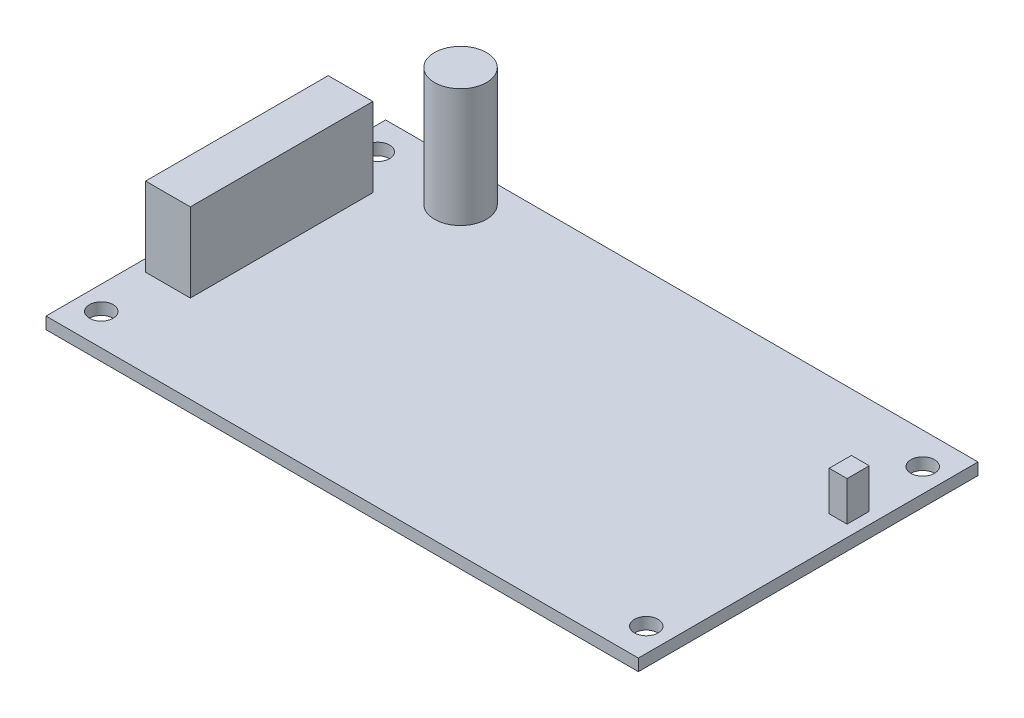
from build123d import *

# Parameters (mm, degrees)
SKETCH1_W           = 75
SKETCH1_H           = 43
SKETCH1_R           = 1.5
BOSS_EXTRUDE1_DEPTH = 1.5
SKETCH3_W           = 5.662945026
SKETCH3_H           = 23.11722764
BOSS_EXTRUDE2_DEPTH = 10
SKETCH4_W           = 2.260398275
SKETCH4_H           = 2.806011651
BOSS_EXTRUDE3_DEPTH = 5
SKETCH5_R           = 3.292125191
BOSS_EXTRUDE4_DEPTH = 15


with BuildPart() as part:
    # Sketch1 → Boss-Extrude1 (new body)
    with BuildSketch(Plane(origin=(0, 0, 0), x_dir=(1, 0, 0), z_dir=(0, 1, 0))):
        Rectangle(SKETCH1_W, SKETCH1_H)
        with Locations((-34.5, 17.5)):
            Circle(SKETCH1_R, mode=Mode.SUBTRACT)
        with Locations((-34.5, -17.5)):
            Circle(SKETCH1_R, mode=Mode.SUBTRACT)
        with Locations((34.5, -17.5)):
            Circle(SKETCH1_R, mode=Mode.SUBTRACT)
        with Locations((34.5, 17.5)):
            Circle(SKETCH1_R, mode=Mode.SUBTRACT)
    extrude(amount=BOSS_EXTRUDE1_DEPTH)

    # Sketch3 → Boss-Extrude2 (add)
    with BuildSketch(Plane(origin=(0, 1.5, 0), x_dir=(1, 0, 0), z_dir=(0, 1, 0))):
        with Locations((-33.163136966, 1.163618841)):
            Rectangle(SKETCH3_W, SKETCH3_H)
    extrude(amount=BOSS_EXTRUDE2_DEPTH)

    # Sketch4 → Boss-Extrude3 (add)
    with BuildSketch(Plane(origin=(0, 1.5, 0), x_dir=(1, 0, 0), z_dir=(0, 1, 0))):
        with Locations((34.903340681, 7.794476809)):
            Rectangle(SKETCH4_W, SKETCH4_H)
    extrude(amount=BOSS_EXTRUDE3_DEPTH)

    # Sketch5 → Boss-Extrude4 (add)
    with BuildSketch(Plane(origin=(0, 1.5, 0), x_dir=(1, 0, 0), z_dir=(0, 1, 0))):
        with Locations((-23.505100586, 16.988835077)):
            Circle(SKETCH5_R)
    extrude(amount=BOSS_EXTRUDE4_DEPTH)


solid = part.part
